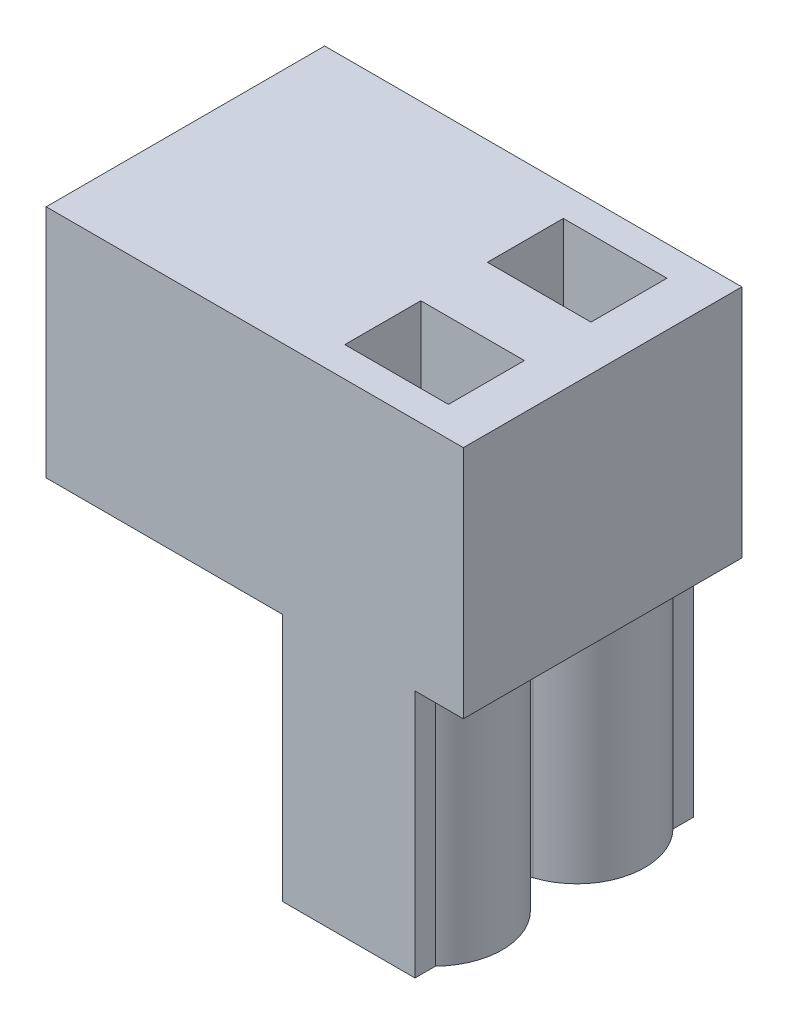
from build123d import *

# Parameters (mm, degrees)
SKETCH1_W           = 15.1
SKETCH1_H           = 10.08
BOSS_EXTRUDE1_DEPTH = 8.5
SKETCH2_R           = 0.55
BOSS_EXTRUDE2_DEPTH = 9
SKETCH3_R           = 1.875
CUT_EXTRUDE1_DEPTH  = 2
CUT_EXTRUDE2_DEPTH  = 2.75
SKETCH4_W           = 3.75
SKETCH4_H           = 2.75
CUT_EXTRUDE3_DEPTH  = 2.9


with BuildPart() as part:
    # Sketch1 → Boss-Extrude1 (new body)
    with BuildSketch(Plane(origin=(0, 0, 0), x_dir=(1, 0, 0), z_dir=(0, 1, 0))):
        Rectangle(SKETCH1_W, SKETCH1_H)
    extrude(amount=BOSS_EXTRUDE1_DEPTH)

    # Sketch2 → Boss-Extrude2 (add)
    with BuildSketch(Plane.XZ):
        with BuildLine():
            Line((5.8, 4.298720454), (5.8, 5.04))
            Line((5.8, 5.04), (1, 5.04))
            Line((1, 5.04), (1, 4.04))
            Line((1, 4.04), (1.75, 4.04))
            Line((1.75, 4.04), (1.75, 1.12))
            Line((1.75, 1.12), (1, 1.12))
            Line((1, 1.12), (1, -1.12))
            Line((1, -1.12), (1.75, -1.12))
            Line((1.75, -1.12), (1.75, -4.04))
            Line((1.75, -4.04), (1, -4.04))
            Line((1, -4.04), (1, -5.04))
            Line((1, -5.04), (5.8, -5.04))
            Line((5.8, -5.04), (5.8, -4.298720454))
            ThreePointArc((5.8, -4.298720454), (6.427646859, -1.987764848), (4.792775244, -0.23800738))
            ThreePointArc((4.792775244, -0.23800738), (4.619276793, 0), (4.792775244, 0.23800738))
            ThreePointArc((4.792775244, 0.23800738), (6.427646859, 1.987764848), (5.8, 4.298720454))
        make_face()
        with Locations((4.04, 2.58)):
            Circle(SKETCH2_R, mode=Mode.SUBTRACT)
        with Locations((4.04, -2.58)):
            Circle(SKETCH2_R, mode=Mode.SUBTRACT)
    extrude(amount=BOSS_EXTRUDE2_DEPTH)

    # Sketch3 → Cut-Extrude1 (cut)
    with BuildSketch(Plane.ZY.offset(7.55)):
        with Locations((-2.58, 3.225)):
            Circle(SKETCH3_R)
        with Locations((2.58, 3.225)):
            Circle(SKETCH3_R)
    extrude(amount=-CUT_EXTRUDE1_DEPTH, mode=Mode.SUBTRACT)

    # Sketch3_3 → Cut-Extrude2 (cut)
    with BuildSketch(Plane.ZY.offset(7.55)):
        with BuildLine():
            Line((-0.729155598, 3.525), (-4.430844402, 3.525))
            ThreePointArc((-4.430844402, 3.525), (-4.455, 3.225), (-4.430844402, 2.925))
            Line((-4.430844402, 2.925), (-0.729155598, 2.925))
            ThreePointArc((-0.729155598, 2.925), (-0.705, 3.225), (-0.729155598, 3.525))
        make_face()
        with BuildLine():
            Line((0.729155598, 2.925), (4.430844402, 2.925))
            ThreePointArc((4.430844402, 2.925), (4.455, 3.225), (4.430844402, 3.525))
            Line((4.430844402, 3.525), (0.729155598, 3.525))
            ThreePointArc((0.729155598, 3.525), (0.705, 3.225), (0.729155598, 2.925))
        make_face()
    extrude(amount=-CUT_EXTRUDE2_DEPTH, mode=Mode.SUBTRACT)

    # Sketch4 → Cut-Extrude3 (cut)
    with BuildSketch(Plane(origin=(0, 8.5, 0), x_dir=(1, 0, 0), z_dir=(0, 1, 0))):
        with Locations((4.05, -2.58)):
            Rectangle(SKETCH4_W, SKETCH4_H)
        with Locations((4.05, 2.58)):
            Rectangle(SKETCH4_W, SKETCH4_H)
    extrude(amount=-CUT_EXTRUDE3_DEPTH, mode=Mode.SUBTRACT)


solid = part.part
